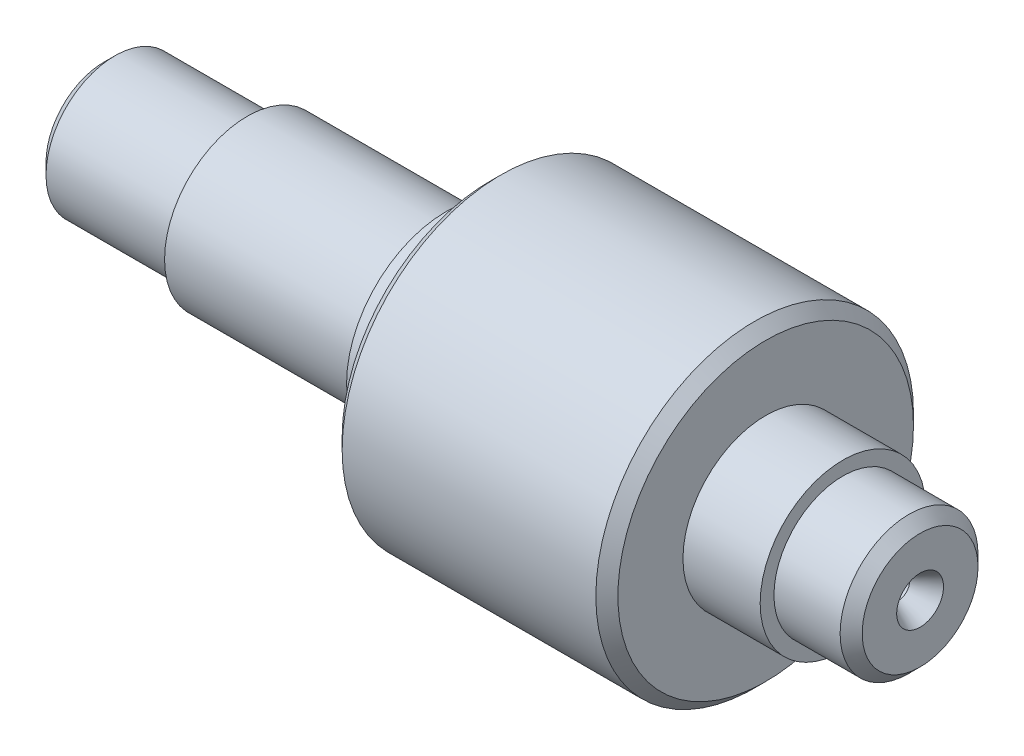
from build123d import *

# Parameters (mm, degrees)
CUT_EXTRUDE_START   = -10
CUT_EXTRUDE_1_DEPTH = 10
CHAMFER_1_SIZE      = 2


with BuildPart() as part:
    # Эскиз2 → Повернуть1 (revolve)
    with BuildSketch(Plane.XY):
        Polygon((0, 0), (148, 0), (148, -12.5), (134, -12.5), (134, -15), (120, -15), (120, -28.8), (70, -28.8), (70, -18), (62, -18), (62, -15), (26, -15), (26, -12.5), (0, -12.5), align=None)
    revolve(axis=Axis((0, 0, 0), (1, 0, 0)))

    # Эскиз3 → Вырез-Повернуть1 (revolve, cut)
    with BuildSketch(Plane.XY):
        Polygon((0, 0), (10.054700538, 0), (8.9, 2), (3.9, 2), (0, 4.25), align=None)
    cut_revolve_1 = revolve(axis=Axis((0, 0, 0), (1, 0, 0)), mode=Mode.SUBTRACT)

    # Зеркальное отражение1: Вырез-Повернуть1 across plane
    add(cut_revolve_1.mirror(Plane(origin=(74, 0, 0), x_dir=(0, 0, 1), z_dir=(1, 0, 0))), mode=Mode.SUBTRACT)

    # Эскиз4 → Вырез-Вытянуть1 (cut)
    with BuildSketch(Plane.XY.offset(CUT_EXTRUDE_START)):
        with BuildLine():
            Line((37, 4), (51, 4))
            ThreePointArc((51, 4), (55, 0), (51, -4))
            Line((51, -4), (37, -4))
            ThreePointArc((37, -4), (33, 0), (37, 4))
        make_face()
    extrude(amount=-CUT_EXTRUDE_1_DEPTH, mode=Mode.SUBTRACT)

    # Фаска1
    chamfer_1_edges = [part.edges().sort_by_distance(p)[0] for p in [
        (0, 12.5, 0),
        (70, 28.8, 0),
        (120, 28.8, 0),
        (148, 12.5, 0),
    ]]
    chamfer(chamfer_1_edges, length=CHAMFER_1_SIZE)


solid = part.part
